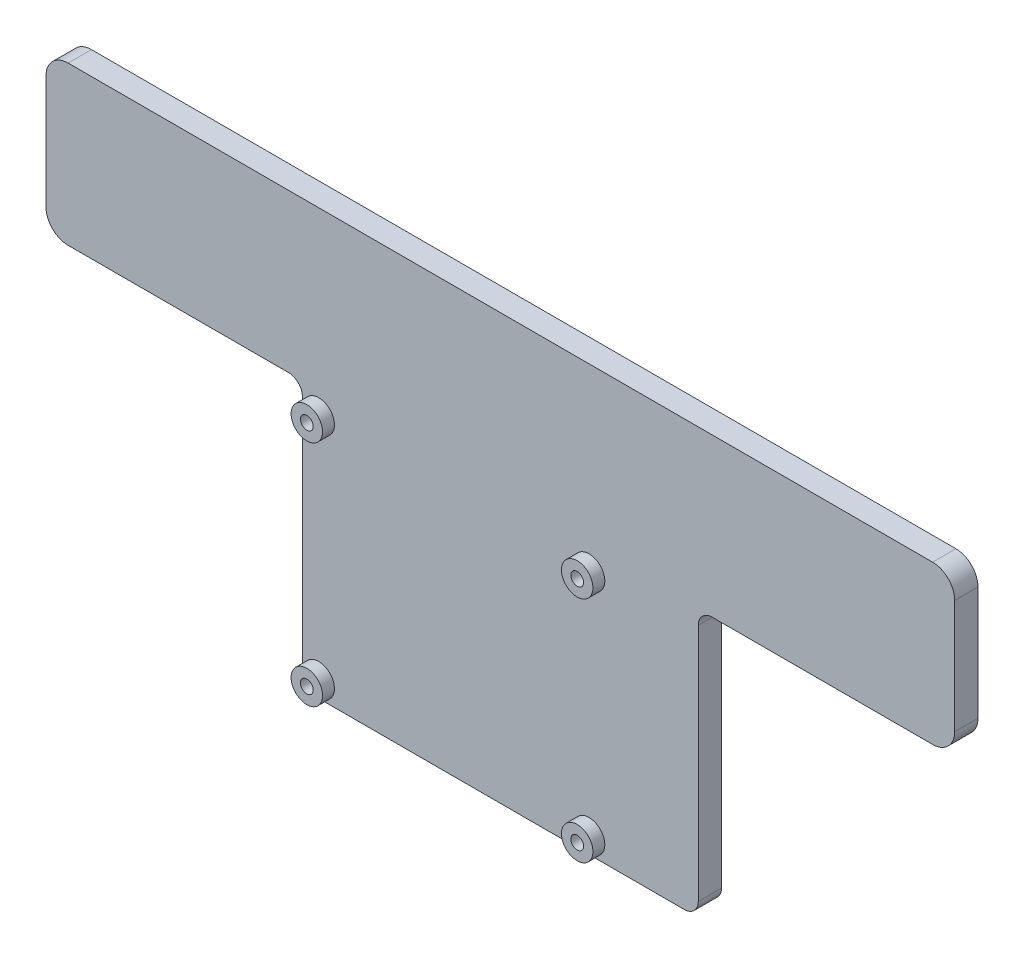
from build123d import *

# Parameters (mm, degrees)
GRUNDFORM_R                     = 1.375
AUFSATZ_LINEAR_AUSTRAGEN1_DEPTH = 5
SKIZZE2_R                       = 3.375
SKIZZE2_R_2                     = 1.375
AUFSATZ_LINEAR_AUSTRAGEN2_DEPTH = 2.554396


with BuildPart() as part:
    # Grundform → Aufsatz-Linear austragen1 (new body)
    with BuildSketch(Plane.XY):
        with BuildLine():
            Line((-93.287044917, 40.781629135), (92.170661923, 40.781629135))
            ThreePointArc((92.170661923, 40.781629135), (95.523773437, 39.39272487), (96.912677703, 36.039613355))
            Line((96.912677703, 36.039613355), (96.912677703, 11.658797868))
            ThreePointArc((96.912677703, 11.658797868), (95.523773437, 8.305686353), (92.170661923, 6.916782087))
            Line((92.170661923, 6.916782087), (44.903892176, 6.916782087))
            ThreePointArc((44.903892176, 6.916782087), (42.782571833, 6.038102431), (41.903892176, 3.916782087))
            Line((41.903892176, 3.916782087), (41.903892176, -47.387842431))
            ThreePointArc((41.903892176, -47.387842431), (41.02521252, -49.509162775), (38.903892176, -50.387842431))
            Line((38.903892176, -50.387842431), (-40.02027517, -50.387842431))
            ThreePointArc((-40.02027517, -50.387842431), (-42.141595514, -49.509162775), (-43.02027517, -47.387842431))
            Line((-43.02027517, -47.387842431), (-43.02027517, 3.916782087))
            ThreePointArc((-43.02027517, 3.916782087), (-43.898954827, 6.038102431), (-46.02027517, 6.916782087))
            Line((-46.02027517, 6.916782087), (-93.287044917, 6.916782087))
            ThreePointArc((-93.287044917, 6.916782087), (-96.640156431, 8.305686353), (-98.029060697, 11.658797868))
            Line((-98.029060697, 11.658797868), (-98.029060697, 36.039613355))
            ThreePointArc((-98.029060697, 36.039613355), (-96.640156431, 39.39272487), (-93.287044917, 40.781629135))
        make_face()
        with Locations((-39.52027517, 2.112157569)):
            Circle(GRUNDFORM_R, mode=Mode.SUBTRACT)
        with Locations((18.47972483, 2.112157569)):
            Circle(GRUNDFORM_R, mode=Mode.SUBTRACT)
        with Locations((18.47972483, -46.887842431)):
            Circle(GRUNDFORM_R, mode=Mode.SUBTRACT)
        with Locations((-39.52027517, -46.887842431)):
            Circle(GRUNDFORM_R, mode=Mode.SUBTRACT)
    extrude(amount=AUFSATZ_LINEAR_AUSTRAGEN1_DEPTH)

    # Skizze2 → Aufsatz-Linear austragen2 (add)
    with BuildSketch(Plane.XY.offset(5)):
        with Locations((-39.52027517, 2.112157569)):
            Circle(SKIZZE2_R)
        with Locations((-39.52027517, 2.112157569)):
            Circle(SKIZZE2_R_2, mode=Mode.SUBTRACT)
        with Locations((18.47972483, 2.112157569)):
            Circle(SKIZZE2_R)
        with Locations((18.47972483, 2.112157569)):
            Circle(SKIZZE2_R_2, mode=Mode.SUBTRACT)
        with Locations((18.47972483, -46.887842431)):
            Circle(SKIZZE2_R)
        with Locations((18.47972483, -46.887842431)):
            Circle(SKIZZE2_R_2, mode=Mode.SUBTRACT)
        with Locations((-39.52027517, -46.887842431)):
            Circle(SKIZZE2_R)
        with Locations((-39.52027517, -46.887842431)):
            Circle(SKIZZE2_R_2, mode=Mode.SUBTRACT)
    extrude(amount=AUFSATZ_LINEAR_AUSTRAGEN2_DEPTH)


solid = part.part
